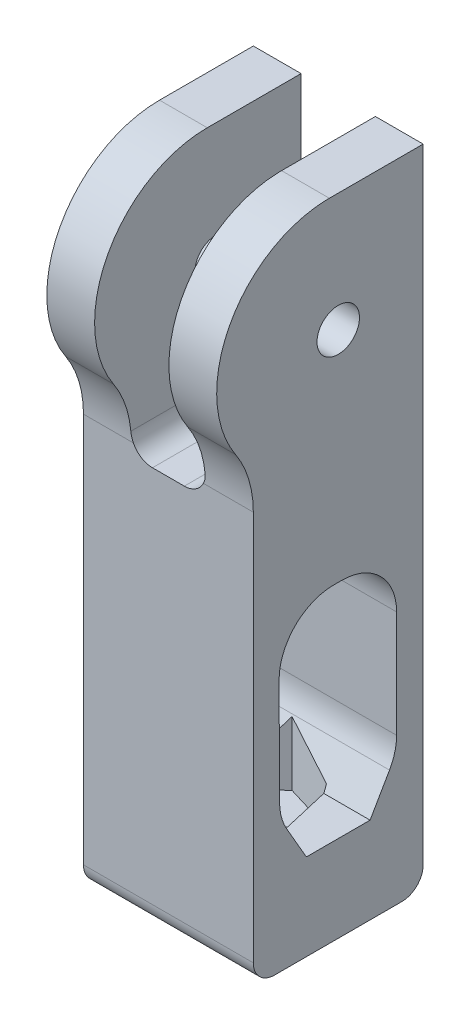
from build123d import *
from OCP.BRepFilletAPI import BRepFilletAPI_MakeChamfer

# Parameters (mm, degrees)
SKETCH9_R                    = 2
BOSS_EXTRUDE3_DEPTH          = 16
SKETCH10_R                   = 2
CUT_EXTRUDE7_DEPTH           = 14
SKETCH11_W                   = 7
SKETCH11_H                   = 26.686138344
CUT_EXTRUDE8_DEPTH           = 28
FILLET1_R                    = 2
CHAMFER1_SIZE                = 2.5
CHAMFER1_SIZE2               = 4.365846821
CHAMFER1_SIZE2_2             = 4.330127019
EXTRUDE1_DEPTH               = 3
EXTRUDE1_DEPTH_BACK          = 3
FILLET2_R                    = 2
FILLET3_R                    = 5
ESTRUSIONE_ESTRUSIONE1_DEPTH = 4.5
ESTRUSIONE_ESTRUSIONE2_DEPTH = 4.5


with BuildPart() as part:
    # Sketch9 → Boss-Extrude3 (new body)
    with BuildSketch(Plane(origin=(0, 0, 0), x_dir=(0, 0, -1), z_dir=(1, 0, 0))):
        with BuildLine():
            Line((8, 5.053889445), (8, -49.642014822))
            Line((8, -49.642014822), (-8, -49.642014822))
            Line((-8, -49.642014822), (-8, -10.875806049))
            ThreePointArc((-8, -10.875806049), (-8.427714838, -7.982476346), (-9.674271354, -5.336650652))
            ThreePointArc((-9.674271354, -5.336650652), (-7.418447874, 8.870328147), (6.925281884, 7.78202542))
            ThreePointArc((6.925281884, 7.78202542), (7.721634556, 6.519985019), (8, 5.053889445))
        make_face()
        Circle(SKETCH9_R, mode=Mode.SUBTRACT)
        with BuildLine():
            Line((5.5, -41.5), (5.5, -25.762364524))
            ThreePointArc((5.5, -25.762364524), (3.987567872, -22.111030369), (0.336233717, -20.598598241))
            Line((0.336233717, -20.598598241), (-0.410415455, -20.598598241))
            ThreePointArc((-0.410415455, -20.598598241), (-4.070351606, -22.119652678), (-5.574124284, -25.786723302))
            Line((-5.574124284, -25.786723302), (-5.5, -41.5))
            Line((-5.5, -41.5), (5.5, -41.5))
        make_face(mode=Mode.SUBTRACT)
    extrude(amount=BOSS_EXTRUDE3_DEPTH)

    # Sketch10 → Cut-Extrude7 (cut)
    with BuildSketch(Plane.XZ.offset(49.642014822)):
        with Locations(Location((8, 0, 0), (0, 0, 270))):
            Circle(SKETCH10_R)
    extrude(amount=-CUT_EXTRUDE7_DEPTH, mode=Mode.SUBTRACT)

    # Sketch11 → Cut-Extrude8 (cut)
    with BuildSketch(Plane(origin=(0, 16, 0), x_dir=(1, 0, 0), z_dir=(0, 1, 0))):
        with Locations((8, -2.737831409)):
            Rectangle(SKETCH11_W, SKETCH11_H)
    extrude(amount=-CUT_EXTRUDE8_DEPTH, mode=Mode.SUBTRACT)

    # Fillet1
    fillet1_edges = [part.edges().sort_by_distance(p)[0] for p in [
        (8, -49.642014822, 8),
        (8, -49.642014822, -8),
    ]]
    fillet(fillet1_edges, radius=FILLET1_R)

    # Chamfer1: one chamfer whose edges measure the first distance from different faces: ONE call of the kernel's chamfer builder (chamfer() names one face for all edges)
    chamfer1_edges_1 = [part.edges().sort_by_distance(p)[0] for p in [
        (8, -41.5, 5.5),
    ]]
    chamfer1_side_1 = [part.faces().sort_by_distance(p)[0] for p in [
        (8, -41.5, 5.305835122),
    ]]
    chamfer1_edges_2 = [part.edges().sort_by_distance(p)[0] for p in [
        (8, -41.5, -5.5),
    ]]
    chamfer1_side_2 = [part.faces().sort_by_distance(p)[0] for p in [
        (8, -41.5, 5.305835122),
    ]]
    chamfer1 = BRepFilletAPI_MakeChamfer(part.part.solid().wrapped)
    for e in chamfer1_edges_1:
        chamfer1.Add(CHAMFER1_SIZE, CHAMFER1_SIZE2, e.wrapped, chamfer1_side_1[0].wrapped)  # the first distance lies on this face
    for e in chamfer1_edges_2:
        chamfer1.Add(CHAMFER1_SIZE, CHAMFER1_SIZE2_2, e.wrapped, chamfer1_side_2[0].wrapped)  # the first distance lies on this face
    add(Compound.cast(chamfer1.Shape()), mode=Mode.REPLACE)

    # Sketch12 → Extrude1 (cut, two sides)
    with BuildSketch(Plane(origin=(0, -41.5, 0), x_dir=(1, 0, 0), z_dir=(0, 1, 0))) as extrude1_sk:
        Polygon((6.895214346, 4.750578313), (3.333485671, 1.418516714), (4.438271325, -3.332061599), (9.104785654, -4.750578313), (12.666514329, -1.418516714), (11.561728675, 3.332061599), align=None)
    extrude(amount=EXTRUDE1_DEPTH, mode=Mode.SUBTRACT)
    extrude(extrude1_sk.sketch, amount=-EXTRUDE1_DEPTH_BACK, mode=Mode.SUBTRACT)

    # Fillet2
    fillet2_edges = [part.edges().sort_by_distance(p)[0] for p in [
        (4.5, -12, 0),
        (11.5, -12, 0),
    ]]
    fillet(fillet2_edges, radius=FILLET2_R)

    # Fillet3
    fillet3_edges = [part.edges().sort_by_distance(p)[0] for p in [
        (8, -37.169872981, -5.5),
        (8, -37.134201755, 5.520594792),
    ]]
    fillet(fillet3_edges, radius=FILLET3_R)

    # Schizzo1 → Estrusione-Estrusione1 (add)
    with BuildSketch(Plane.ZY):
        Polygon((0.837135677, 11.156995776), (-8, 11.156995776), (-8, 4.232261394), (1.127037183, 4.232261394), align=None)
    extrude(amount=-ESTRUSIONE_ESTRUSIONE1_DEPTH)

    # Schizzo2 → Estrusione-Estrusione2 (add)
    with BuildSketch(Plane(origin=(16, 0, 0), x_dir=(0, 0, -1), z_dir=(1, 0, 0))):
        Polygon((-0.837135677, 11.156995776), (8, 11.156995776), (8, 3.955668155), (-3.77094248, 6.198951123), (-1.212549738, 11.150354711), align=None)
    extrude(amount=-ESTRUSIONE_ESTRUSIONE2_DEPTH)


solid = part.part
